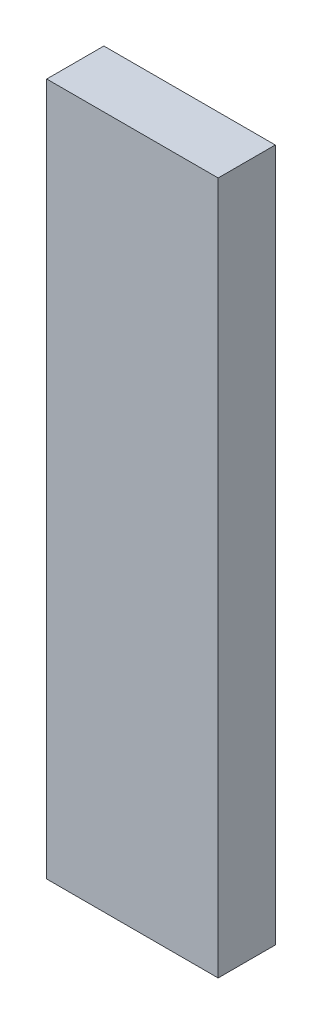
from build123d import *

# Parameters (mm, degrees)
SKETCH1_W           = 38.1
SKETCH1_H           = 12.7
BOSS_EXTRUDE1_DEPTH = 154


with BuildPart() as part:
    # Sketch1 → Boss-Extrude1 (new body)
    with BuildSketch(Plane(origin=(0, 0, 0), x_dir=(1, 0, 0), z_dir=(0, 1, 0))):
        with Locations((19.05, 6.35)):
            Rectangle(SKETCH1_W, SKETCH1_H)
    extrude(amount=BOSS_EXTRUDE1_DEPTH)


solid = part.part
